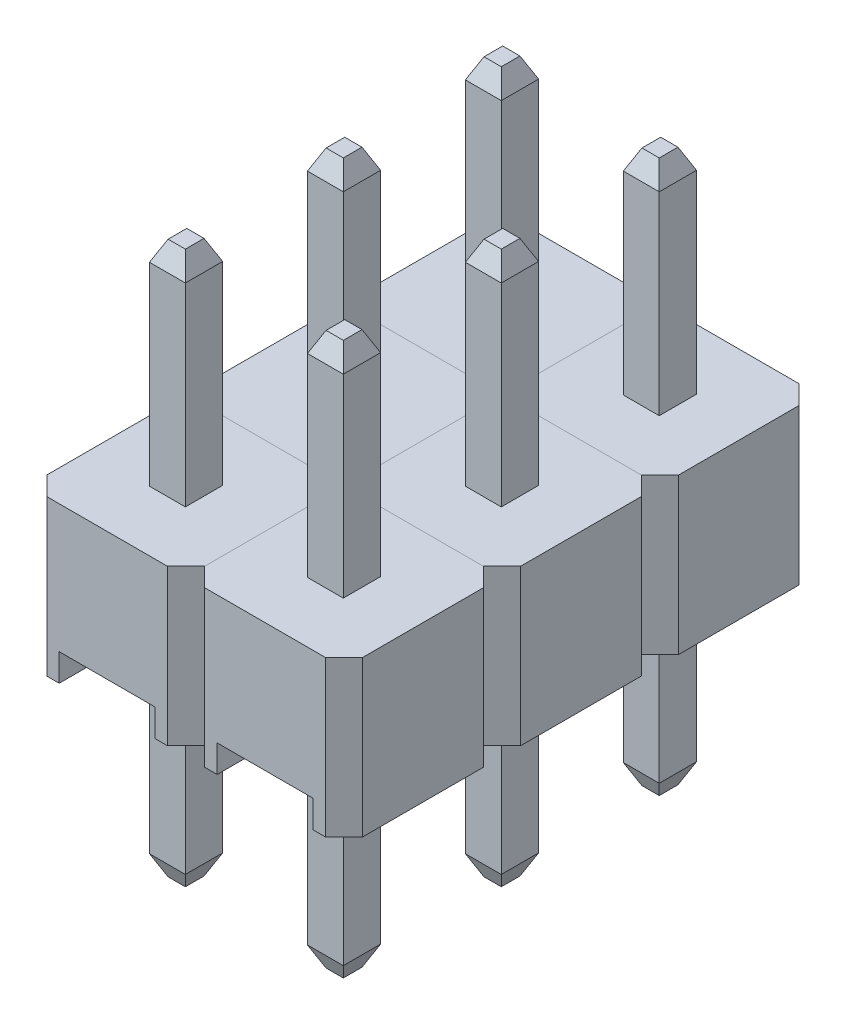
from build123d import *

# Parameters (mm, degrees)
CUERPO_PL_STICO_DEPTH = 2.5
CROQUIS2_W            = 1.54
CROQUIS2_H            = 2.54
RANURA_DEPTH          = 0.44
CROQUIS3_W            = 0.57750613
CROQUIS3_H            = 0.6
PIN_DEPTH             = 3.44
PIN_DEPTH_BACK        = 5.44
CHAFL_N1_SIZE         = 0.15
CHAFL_N1_SIZE2        = 0.321676038
CHAFL_N2_SIZE         = 0.15
CHAFL_N2_SIZE2        = 0.321676038
MATRIZ_COUNT          = 3
MATRIZ_PITCH          = 2.54
MATRIZ_2_COUNT        = 2
MATRIZ_2_PITCH        = 2.54


with BuildPart() as part:
    # Croquis1 → Cuerpo Plástico (new body)
    with BuildSketch(Plane(origin=(0, 0, 0), x_dir=(1, 0, 0), z_dir=(0, 1, 0))):
        Polygon((0.3, 0), (2.24, 0), (2.54, 0.3), (2.54, 2.24), (2.24, 2.54), (0.3, 2.54), (0, 2.24), (0, 0.3), align=None)
    extrude(amount=CUERPO_PL_STICO_DEPTH)

    # Croquis2 → Ranura (cut)
    with BuildSketch(Plane.XZ):
        with Locations((1.27, -1.27)):
            Rectangle(CROQUIS2_W, CROQUIS2_H)
    extrude(amount=-RANURA_DEPTH, mode=Mode.SUBTRACT)

    # Croquis3 → Pin (add, two sides)
    with BuildSketch(Plane(origin=(0, 2.5, 0), x_dir=(1, 0, 0), z_dir=(0, 1, 0))) as pin_sk:
        with Locations((1.27, 1.27)):
            Rectangle(CROQUIS3_W, CROQUIS3_H)
    extrude(amount=PIN_DEPTH)
    extrude(pin_sk.sketch, amount=-PIN_DEPTH_BACK)

    # Chaflán1
    chafl_n1_edges = [part.edges().sort_by_distance(p)[0] for p in [
        (0.981246935, 5.94, -1.27),
        (1.27, 5.94, -0.97),
        (1.558753065, 5.94, -1.27),
        (1.27, 5.94, -1.57),
    ]]
    chafl_n1_side = [part.faces().sort_by_distance(p)[0] for p in [
        (1.27, 5.94, -1.27),
    ]]
    chamfer(chafl_n1_edges, length=CHAFL_N1_SIZE, length2=CHAFL_N1_SIZE2, reference=chafl_n1_side[0])

    # Chaflán2
    chafl_n2_edges = [part.edges().sort_by_distance(p)[0] for p in [
        (0.981246935, -2.94, -1.27),
        (1.27, -2.94, -1.57),
        (1.558753065, -2.94, -1.27),
        (1.27, -2.94, -0.97),
    ]]
    chafl_n2_side = [part.faces().sort_by_distance(p)[0] for p in [
        (1.27, -2.94, -1.27),
    ]]
    chamfer(chafl_n2_edges, length=CHAFL_N2_SIZE, length2=CHAFL_N2_SIZE2, reference=chafl_n2_side[0])


with BuildPart() as matriz_1:
    # Matriz: pattern copy
    add(part.part.moved(Location(Vector(0, 0, 1) * (1 * MATRIZ_PITCH))))


with BuildPart() as matriz_2:
    # Matriz: pattern copy
    add(part.part.moved(Location(Vector(0, 0, 1) * (2 * MATRIZ_PITCH))))


with BuildPart() as matriz_2_1:
    # Matriz 2: pattern copy
    add(part.part.moved(Location(Vector(1, 0, 0) * (1 * MATRIZ_2_PITCH))))


with BuildPart() as matriz_2_2:
    # Matriz 2: pattern copy
    add(matriz_1.part.moved(Location(Vector(1, 0, 0) * (1 * MATRIZ_2_PITCH))))


with BuildPart() as matriz_2_3:
    # Matriz 2: pattern copy
    add(matriz_2.part.moved(Location(Vector(1, 0, 0) * (1 * MATRIZ_2_PITCH))))


solid = Compound([part.part, matriz_1.part, matriz_2.part, matriz_2_1.part, matriz_2_2.part, matriz_2_3.part])
